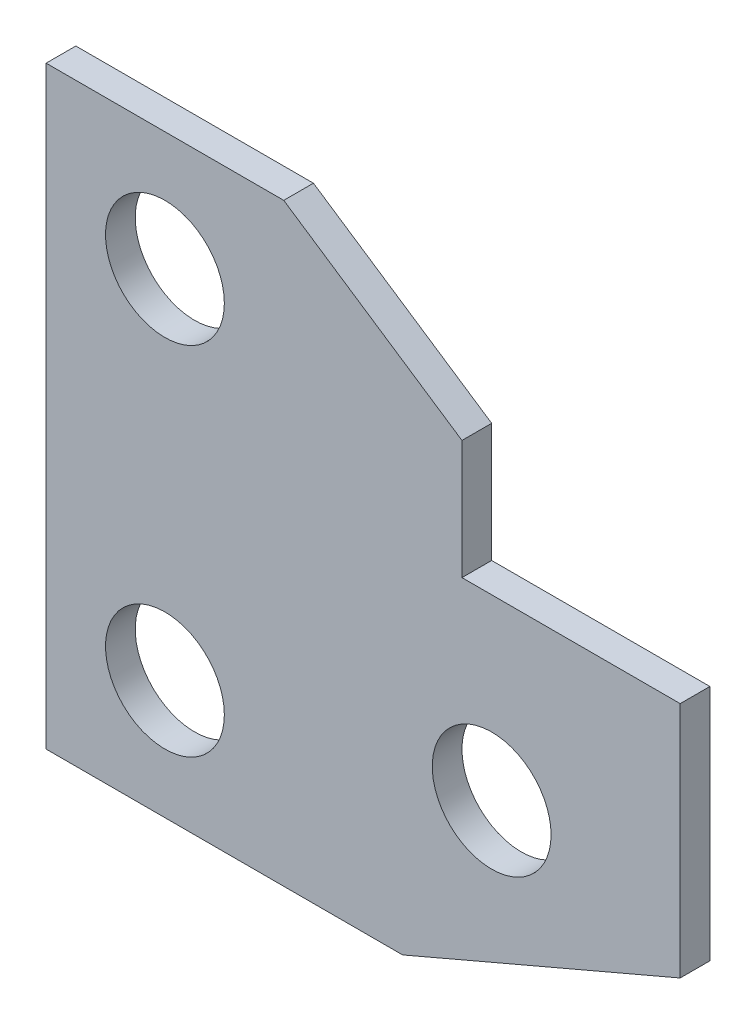
from build123d import *

# Parameters (mm, degrees)
SKETCH2_R           = 10
BOSS_EXTRUDE1_DEPTH = 5


with BuildPart() as part:
    # Sketch2 → Boss-Extrude1 (new body)
    with BuildSketch(Plane.XY):
        Polygon((-146.847208951, 106.235417928), (-106.847208951, 106.235417928), (-76.847208951, 86.235417928), (-76.847208951, 66.235417928), (-40.114098915, 66.235417928), (-40.114098915, 26.235417928), (-86.847208951, 6.235417928), (-146.847208951, 6.235417928), align=None)
        with Locations((-126.847208951, 86.235417928)):
            Circle(SKETCH2_R, mode=Mode.SUBTRACT)
        with Locations((-126.847208951, 26.235417928)):
            Circle(SKETCH2_R, mode=Mode.SUBTRACT)
        with Locations((-71.847208951, 36.235417928)):
            Circle(SKETCH2_R, mode=Mode.SUBTRACT)
    extrude(amount=BOSS_EXTRUDE1_DEPTH)


solid = part.part
